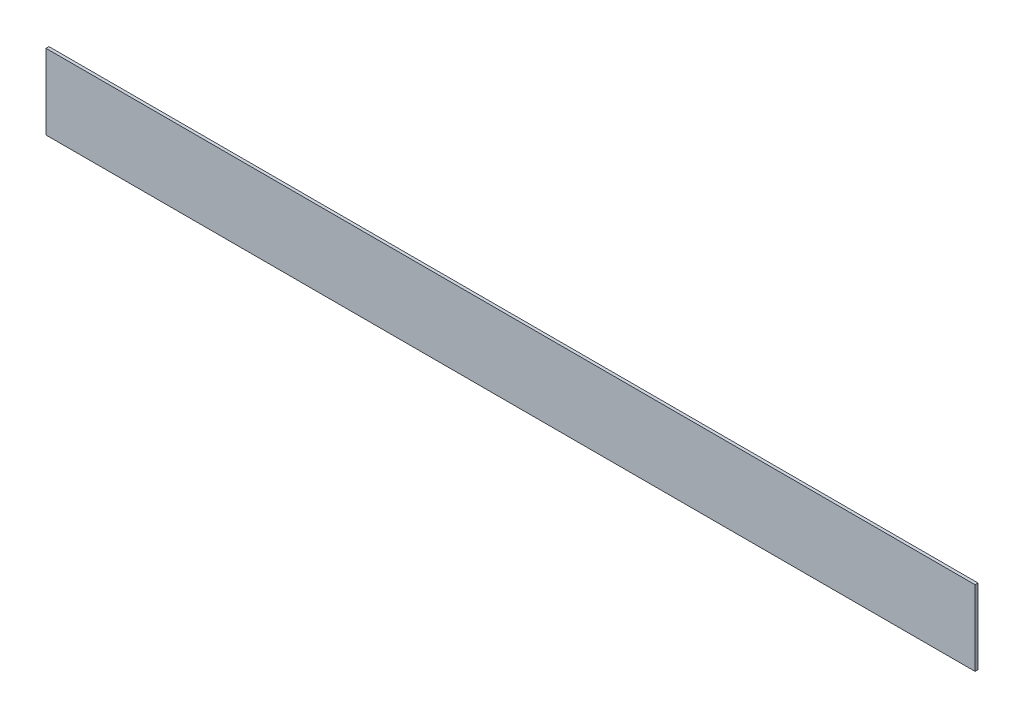
from build123d import *

# Parameters (mm, degrees)
SKETCH1_W           = 2984.5
SKETCH1_H           = 241.3
BOSS_EXTRUDE1_DEPTH = 9.525


with BuildPart() as part:
    # Sketch1 → Boss-Extrude1 (new body)
    with BuildSketch(Plane.XY):
        with Locations((1492.25, 120.65)):
            Rectangle(SKETCH1_W, SKETCH1_H)
    extrude(amount=BOSS_EXTRUDE1_DEPTH)


solid = part.part
